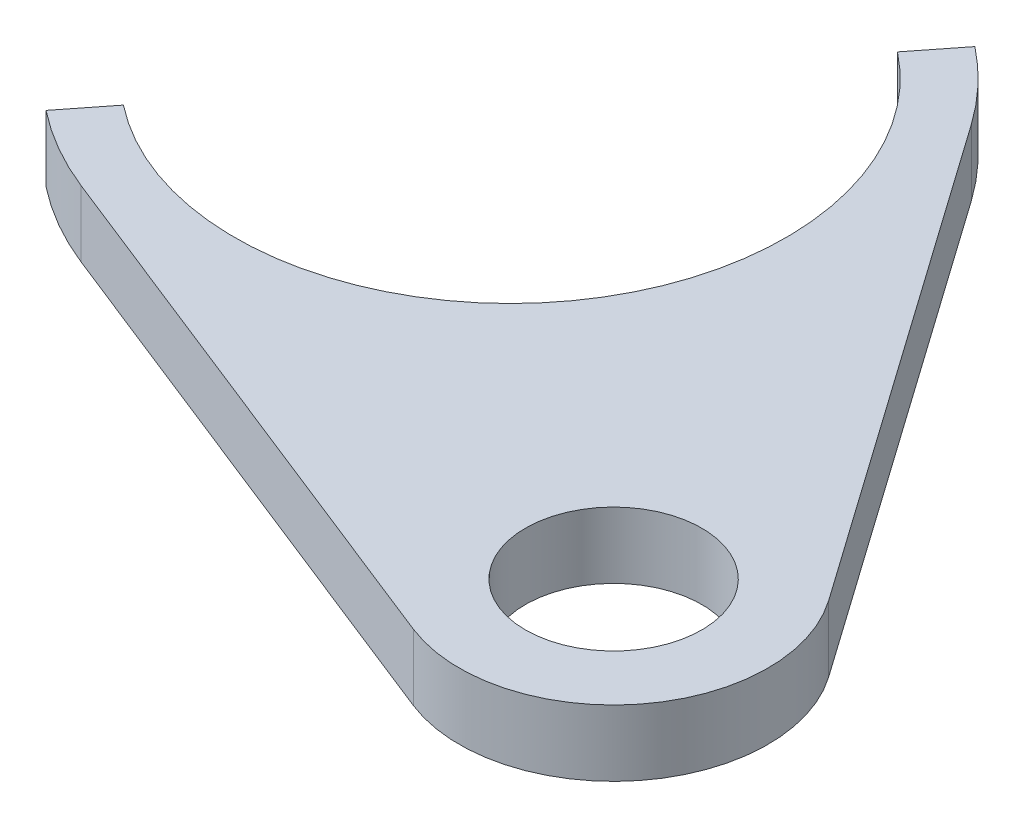
from build123d import *

# Parameters (mm, degrees)
SZKIC1_R                    = 4
DODANIE_WYCI_GNI_CIE1_DEPTH = 3


with BuildPart() as part:
    # Szkic1 → Dodanie-wyciągnięcie1 (new body)
    with BuildSketch(Plane(origin=(0, 0, 0), x_dir=(1, 0, 0), z_dir=(0, 1, 0))):
        with BuildLine():
            Line((-1665.878196442, -141.728418885), (-1690.824706662, -131.845523163))
            ThreePointArc((-1690.824706662, -131.845523163), (-1692.780138286, -130.901827995), (-1694.578843612, -129.685714286))
            Line((-1694.578843612, -129.685714286), (-1693.032369677, -127.721428571))
            ThreePointArc((-1693.032369677, -127.721428571), (-1675.478571429, -125.632369677), (-1677.567630323, -108.078571429))
            Line((-1677.567630323, -108.078571429), (-1676.021156388, -106.114285714))
            ThreePointArc((-1676.021156388, -106.114285714), (-1674.416864421, -107.577337555), (-1673.04059946, -109.256673186))
            Line((-1673.04059946, -109.256673186), (-1657.578946415, -131.186955563))
            ThreePointArc((-1657.578946415, -131.186955563), (-1657.8, -139.550635095), (-1665.878196442, -141.728418885))
        make_face()
        with Locations((-1663.3, -135.220508076)):
            Circle(SZKIC1_R, mode=Mode.SUBTRACT)
    extrude(amount=DODANIE_WYCI_GNI_CIE1_DEPTH)


solid = part.part
